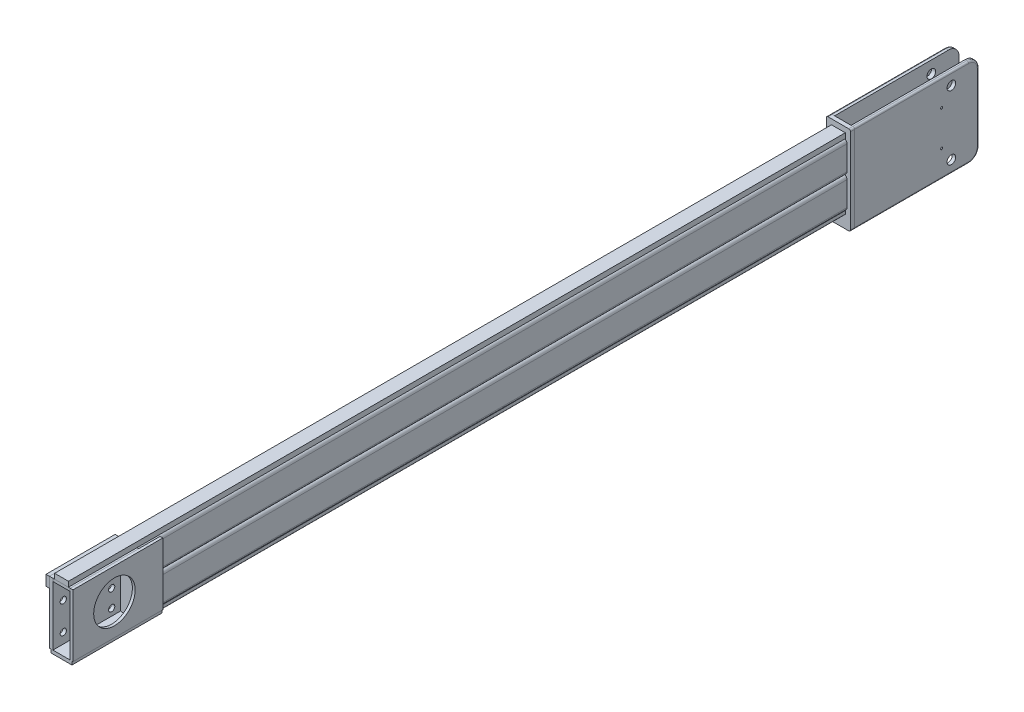
from build123d import *

# Parameters (mm, degrees)
MEMBER_90_60_5_1_DEPTH      = 2050
MEMBER_90_60_5_3_DEPTH      = 2050
EXTRUDE_1_DEPTH             = 8
EXTRUDE_2_DEPTH             = 12
SKETCH_16_W                 = 10
SKETCH_16_H                 = 256
EXTRUDE_3_DEPTH             = 360
SKETCH_16_W_2               = 12
EXTRUDE_3_2_DEPTH           = 360
FILLET_4_R                  = 30
FILLET_5_R                  = 30
FILLET_1_R                  = 5
FILLET_2_R                  = 5
SKETCH_17_W                 = 40
SKETCH_17_H                 = 1990
EXTRUDE_4_DEPTH             = 10
FILLET_6_R                  = 1
CUT_EXTRUDE_START           = -70
SKETCH_18_R                 = 12.5
CUT_EXTRUDE_1_DEPTH         = 70
HOLE_WIZARD_M6_1_AT_2_COUNT = 2
HOLE_WIZARD_M6_1_AT_2_PITCH = 101.5
SKETCH_21_W                 = 60
SKETCH_21_H                 = 10
EXTRUDE_5_DEPTH             = 190
SKETCH_22_W                 = 260
SKETCH_22_H                 = 180
EXTRUDE_6_DEPTH             = 10
SKETCH_23_W                 = 260
SKETCH_23_H                 = 180
EXTRUDE_7_DEPTH             = 8
SKETCH_24_W                 = 50
SKETCH_24_H                 = 198
EXTRUDE_9_DEPTH             = 8
SKETCH_25_R                 = 60
CUT_EXTRUDE_2_DEPTH         = 8
SKETCH_26_R                 = 9
CUT_EXTRUDE_3_DEPTH         = 10
SKETCH_27_W                 = 200
SKETCH_27_H                 = 30
EXTRUDE_10_DEPTH            = 10
SKETCH_34_W                 = 60
SKETCH_34_H                 = 10
EXTRUDE_15_DEPTH            = 70
SKETCH_29_R                 = 9
CUT_EXTRUDE_4_DEPTH         = 12
SKETCH_30_W                 = 290
SKETCH_30_H                 = 30
EXTRUDE_12_DEPTH            = 10
SKETCH_31_W                 = 50
SKETCH_31_H                 = 60
CUT_EXTRUDE_5_DEPTH         = 10
SKETCH_32_W                 = 60
SKETCH_32_H                 = 10
EXTRUDE_13_DEPTH            = 60
SKETCH_33_W                 = 40
SKETCH_33_H                 = 2248
EXTRUDE_14_DEPTH            = 15
SKETCH_37_W                 = 3.4
SKETCH_37_H                 = 5.001
HOLE_WIZARD_M8_1_AT_2_COUNT = 2
HOLE_WIZARD_M8_1_AT_2_PITCH = 80
HOLE_WIZARD_M8_1_AT_3_COUNT = 2
HOLE_WIZARD_M8_1_AT_3_PITCH = 40
HOLE_WIZARD_M8_1_AT_4_COUNT = 2
HOLE_WIZARD_M8_1_AT_4_PITCH = 89.4427191
SKETCH_38_R                 = 6
CUT_EXTRUDE_6_DEPTH         = 12


with BuildPart() as part:
    # 草图11 → Member 90_60_5_1 (new body)
    with BuildSketch(Plane(origin=(15, 55, 0), x_dir=(1, 0, 0), z_dir=(0, 0, -1))):
        with BuildLine():
            Line((-15, -35), (15, -35))
            ThreePointArc((15, -35), (22.071067812, -32.071067812), (25, -25))
            Line((25, -25), (25, 45))
            ThreePointArc((25, 45), (22.071067812, 52.071067812), (15, 55))
            Line((15, 55), (-15, 55))
            ThreePointArc((-15, 55), (-22.071067812, 52.071067812), (-25, 45))
            Line((-25, 45), (-25, -25))
            ThreePointArc((-25, -25), (-22.071067812, -32.071067812), (-15, -35))
        make_face()
        with BuildLine():
            Line((-15, 50), (15, 50))
            ThreePointArc((15, 50), (18.535533906, 48.535533906), (20, 45))
            Line((20, 45), (20, -25))
            ThreePointArc((20, -25), (18.535533906, -28.535533906), (15, -30))
            Line((15, -30), (-15, -30))
            ThreePointArc((-15, -30), (-18.535533906, -28.535533906), (-20, -25))
            Line((-20, -25), (-20, 45))
            ThreePointArc((-20, 45), (-18.535533906, 48.535533906), (-15, 50))
        make_face(mode=Mode.SUBTRACT)
    extrude(amount=MEMBER_90_60_5_1_DEPTH)


with BuildPart() as body_2:
    # 草图12 → Member 90_60_5_3 (new body)
    with BuildSketch(Plane(origin=(15, -35, 0), x_dir=(1, 0, 0), z_dir=(0, 0, -1))):
        with BuildLine():
            Line((-15, -35), (15, -35))
            ThreePointArc((15, -35), (22.071067812, -32.071067812), (25, -25))
            Line((25, -25), (25, 45))
            ThreePointArc((25, 45), (22.071067812, 52.071067812), (15, 55))
            Line((15, 55), (-15, 55))
            ThreePointArc((-15, 55), (-22.071067812, 52.071067812), (-25, 45))
            Line((-25, 45), (-25, -25))
            ThreePointArc((-25, -25), (-22.071067812, -32.071067812), (-15, -35))
        make_face()
        with BuildLine():
            Line((-15, 50), (15, 50))
            ThreePointArc((15, 50), (18.535533906, 48.535533906), (20, 45))
            Line((20, 45), (20, -25))
            ThreePointArc((20, -25), (18.535533906, -28.535533906), (15, -30))
            Line((15, -30), (-15, -30))
            ThreePointArc((-15, -30), (-18.535533906, -28.535533906), (-20, -25))
            Line((-20, -25), (-20, 45))
            ThreePointArc((-20, 45), (-18.535533906, 48.535533906), (-15, 50))
        make_face(mode=Mode.SUBTRACT)
    extrude(amount=MEMBER_90_60_5_3_DEPTH)



with BuildPart() as body_3:
    # 草图14 → 凸台-拉伸1 (new body)
    with BuildSketch(Plane.XY):
        with BuildLine():
            Line((45, 80), (45, -80))
            ThreePointArc((45, -80), (43.535533906, -83.535533906), (40, -85))
            Line((40, -85), (0, -85))
            ThreePointArc((0, -85), (-3.535533906, -83.535533906), (-5, -80))
            Line((-5, -80), (-5, 80))
            ThreePointArc((-5, 80), (-3.535533906, 83.535533906), (0, 85))
            Line((0, 85), (40, 85))
            ThreePointArc((40, 85), (43.535533906, 83.535533906), (45, 80))
        make_face()
    extrude(amount=EXTRUDE_1_DEPTH)


with BuildPart() as body_4:
    # 草图15 → 凸台-拉伸2 (new body)
    with BuildSketch(Plane(origin=(0, 0, -2050), x_dir=(-1, 0, 0), z_dir=(0, 0, -1))):
        with BuildLine():
            Line((-50, 115), (-50, -131))
            ThreePointArc((-50, -131), (-48.535533906, -134.535533906), (-45, -136))
            Line((-45, -136), (15, -136))
            ThreePointArc((15, -136), (18.535533906, -134.535533906), (20, -131))
            Line((20, -131), (20, 115))
            ThreePointArc((20, 115), (18.535533906, 118.535533906), (15, 120))
            Line((15, 120), (-45, 120))
            ThreePointArc((-45, 120), (-48.535533906, 118.535533906), (-50, 115))
        make_face()
    extrude(amount=EXTRUDE_2_DEPTH)


with BuildPart() as body_5:
    # 草图16 → 凸台-拉伸3 (new body)
    with BuildSketch(Plane(origin=(0, 0, -2062), x_dir=(-1, 0, 0), z_dir=(0, 0, -1))):
        with Locations((-45, -8)):
            Rectangle(SKETCH_16_W, SKETCH_16_H)
    extrude(amount=EXTRUDE_3_DEPTH)

    # 圆角4
    fillet_4_edges = [body_5.edges().sort_by_distance(p)[0] for p in [
        (45, -136, -2422),
        (45, 120, -2422),
    ]]
    fillet(fillet_4_edges, radius=FILLET_4_R)

    # 圆角1
    fillet_1_edges = [body_5.edges().sort_by_distance(p)[0] for p in [
        (50, -8, -2422),
        (50, -136, -2227),
        (50, 120, -2227),
        (50, 111.213203436, -2413.213203436),
        (50, -127.213203436, -2413.213203436),
    ]]
    fillet(fillet_1_edges, radius=FILLET_1_R)


with BuildPart() as body_6:
    # 草图16 → Extrude 3 2 (new body)
    with BuildSketch(Plane(origin=(0, 0, -2062), x_dir=(-1, 0, 0), z_dir=(0, 0, -1))):
        with Locations((14, -8)):
            Rectangle(SKETCH_16_W_2, SKETCH_16_H)
    extrude(amount=EXTRUDE_3_2_DEPTH)

    # 圆角5
    fillet_5_edges = [body_6.edges().sort_by_distance(p)[0] for p in [
        (-14, 120, -2422),
        (-14, -136, -2422),
    ]]
    fillet(fillet_5_edges, radius=FILLET_5_R)

    # 圆角2
    fillet_2_edges = [body_6.edges().sort_by_distance(p)[0] for p in [
        (-20, -8, -2422),
        (-20, 120, -2227),
        (-20, -136, -2227),
        (-20, 111.213203436, -2413.213203436),
        (-20, -127.213203436, -2413.213203436),
    ]]
    fillet(fillet_2_edges, radius=FILLET_2_R)


with BuildPart() as body_7:
    # 草图17 → 凸台-拉伸4 (new body)
    with BuildSketch(Plane.XZ.offset(90)):
        with Locations((15, -1055)):
            Rectangle(SKETCH_17_W, SKETCH_17_H)
    extrude(amount=EXTRUDE_4_DEPTH)

    # 圆角6
    fillet_6_edges = [body_7.edges().sort_by_distance(p)[0] for p in [
        (-5, -100, -1055),
        (35, -100, -1055),
    ]]
    fillet(fillet_6_edges, radius=FILLET_6_R)


with BuildPart() as cut_extrude_1_tool:
    # 草图18 → 切除-拉伸1 (new body)
    with BuildSketch(Plane.ZY.offset(20).offset(CUT_EXTRUDE_START)):
        with Locations(Location((-2342, 85, 0), (0, 0, 270))):
            Circle(SKETCH_18_R)
        with Locations(Location((-2342, -101, 0), (0, 0, 270))):
            Circle(SKETCH_18_R)
    extrude(amount=CUT_EXTRUDE_1_DEPTH)


with BuildPart() as body_5_1:
    add(body_5.part)

    # 切除-拉伸1: cut by cut_extrude_1_tool
    add(cut_extrude_1_tool.part, mode=Mode.SUBTRACT)

    # 草图20 → M6 螺纹孔1 (revolve, cut)
    with BuildSketch(Plane(origin=(50, 42.75, -2314), x_dir=(0, 0, -1), z_dir=(0, 1, 0))):
        Polygon((0, 0), (0, 10.001), (2.5, 10.001), (2.5, 0.525), (3.025, 0), align=None)
    hole_wizard_m6_1 = revolve(axis=Axis((56.35, 42.75, -2314), (-1, 0, 0)), mode=Mode.SUBTRACT)

    # M6 螺纹孔1 at 2: M6 螺纹孔1 ×2
    with Locations(*[(0, -i * HOLE_WIZARD_M6_1_AT_2_PITCH, 0) for i in range(1, HOLE_WIZARD_M6_1_AT_2_COUNT)]):
        add(hole_wizard_m6_1, mode=Mode.SUBTRACT)


with BuildPart() as body_6_1:
    add(body_6.part)

    # 切除-拉伸1: cut by cut_extrude_1_tool
    add(cut_extrude_1_tool.part, mode=Mode.SUBTRACT)

    # 草图29 → 切除-拉伸4 (cut)
    with BuildSketch(Plane.ZY.offset(20)):
        with Locations(Location((-2102, 30, 0), (0, 0, 270))):
            Circle(SKETCH_29_R)
        with Locations(Location((-2102, -20, 0), (0, 0, 270))):
            Circle(SKETCH_29_R)
        with Locations(Location((-2102, -70, 0), (0, 0, 270))):
            Circle(SKETCH_29_R)
        with Locations(Location((-2187, -20, 0), (0, 0, 270))):
            Circle(SKETCH_29_R)
        with Locations(Location((-2187, 30, 0), (0, 0, 270))):
            Circle(SKETCH_29_R)
        with Locations(Location((-2272, 20, 0), (0, 0, 270))):
            Circle(SKETCH_29_R)
        with Locations(Location((-2272, -50, 0), (0, 0, 270))):
            Circle(SKETCH_29_R)
        with Locations(Location((-2187, -70, 0), (0, 0, 270))):
            Circle(SKETCH_29_R)
    extrude(amount=-CUT_EXTRUDE_4_DEPTH, mode=Mode.SUBTRACT)

    # 草图38 → 切除-拉伸6 (cut)
    with BuildSketch(Plane.ZY.offset(20)):
        with Locations(Location((-2392, -56, 0), (0, 0, 270))):
            Circle(SKETCH_38_R)
        with Locations(Location((-2352, -26, 0), (0, 0, 270))):
            Circle(SKETCH_38_R)
        with Locations(Location((-2392, 4, 0), (0, 0, 270))):
            Circle(SKETCH_38_R)
    extrude(amount=-CUT_EXTRUDE_6_DEPTH, mode=Mode.SUBTRACT)


with BuildPart() as body_8:
    # 草图21 → 凸台-拉伸5 (new body)
    with BuildSketch(Plane.XY.offset(8)):
        with Locations((15, -95)):
            Rectangle(SKETCH_21_W, SKETCH_21_H)
    extrude(amount=EXTRUDE_5_DEPTH)


with BuildPart() as body_9:
    # 草图22 → 凸台-拉伸6 (new body)
    with BuildSketch(Plane.ZY.offset(10)):
        with Locations((68, 0)):
            Rectangle(SKETCH_22_W, SKETCH_22_H)
    extrude(amount=EXTRUDE_6_DEPTH)

    # 草图26 → 切除-拉伸3 (cut)
    with BuildSketch(Plane.ZY.offset(20)):
        with Locations(Location((98, -20, 0), (0, 0, 270))):
            Circle(SKETCH_26_R)
        with Locations(Location((98, 30, 0), (0, 0, 270))):
            Circle(SKETCH_26_R)
        with Locations(Location((98, -70, 0), (0, 0, 270))):
            Circle(SKETCH_26_R)
        with Locations(Location((168, -60, 0), (0, 0, 270))):
            Circle(SKETCH_26_R)
        with Locations(Location((168, 20, 0), (0, 0, 270))):
            Circle(SKETCH_26_R)
        with Locations(Location((28, -70, 0), (0, 0, 270))):
            Circle(SKETCH_26_R)
        with Locations(Location((28, -20, 0), (0, 0, 270))):
            Circle(SKETCH_26_R)
        with Locations(Location((28, 30, 0), (0, 0, 270))):
            Circle(SKETCH_26_R)
    extrude(amount=-CUT_EXTRUDE_3_DEPTH, mode=Mode.SUBTRACT)


with BuildPart() as body_10:
    # 草图23 → 凸台-拉伸7 (new body)
    with BuildSketch(Plane(origin=(40, 0, 0), x_dir=(0, 0, -1), z_dir=(1, 0, 0))):
        with Locations((-68, 0)):
            Rectangle(SKETCH_23_W, SKETCH_23_H)
    extrude(amount=EXTRUDE_7_DEPTH)

    # 草图25 → 切除-拉伸2 (cut)
    with BuildSketch(Plane(origin=(48, 0, 0), x_dir=(0, 0, -1), z_dir=(1, 0, 0))):
        with Locations(Location((-78, 0, 0), (0, 0, 90))):
            Circle(SKETCH_25_R)
    extrude(amount=-CUT_EXTRUDE_2_DEPTH, mode=Mode.SUBTRACT)


with BuildPart() as body_11:
    # 草图24 → 凸台-拉伸9 (new body)
    with BuildSketch(Plane(origin=(0, 90, 0), x_dir=(1, 0, 0), z_dir=(0, 1, 0))):
        with Locations((15, -99)):
            Rectangle(SKETCH_24_W, SKETCH_24_H)
    extrude(amount=-EXTRUDE_9_DEPTH)


with BuildPart() as body_12:
    # 草图27 → 凸台-拉伸10 (new body)
    with BuildSketch(Plane.ZY.offset(20)):
        with Locations((98, 75)):
            Rectangle(SKETCH_27_W, SKETCH_27_H)
    extrude(amount=EXTRUDE_10_DEPTH)


with BuildPart() as body_2_1:
    add(body_2.part)

    add(body_7.part)  # 凸台-拉伸15 merges body 7

    add(body_8.part)  # 凸台-拉伸15 merges body 8

    add(body_9.part)  # 凸台-拉伸15 merges body 9

    add(body_10.part)  # 凸台-拉伸15 merges body 10
    # 草图34 → 凸台-拉伸15 (add)
    with BuildSketch(Plane(origin=(0, 0, 8), x_dir=(-1, 0, 0), z_dir=(0, 0, -1))):
        with Locations((-15, -95)):
            Rectangle(SKETCH_34_W, SKETCH_34_H)
    extrude(amount=EXTRUDE_15_DEPTH)

    # 草图31 → 切除-拉伸5 (cut)
    with BuildSketch(Plane.XZ.offset(100)):
        with Locations((15, -32)):
            Rectangle(SKETCH_31_W, SKETCH_31_H)
    extrude(amount=-CUT_EXTRUDE_5_DEPTH, mode=Mode.SUBTRACT)

    # 草图37 → M8 螺纹孔的螺纹孔钻头1 (revolve, cut)
    with BuildSketch(Plane(origin=(-10, -65.505102572, -1772.019231054), x_dir=(0, 0, 1), z_dir=(0, 1, 0))):
        with Locations((1.7, 2.5005)):
            Rectangle(SKETCH_37_W, SKETCH_37_H)
    hole_wizard_m8_1 = revolve(axis=Axis((-16.35, -65.505102572, -1772.019231054), (1, 0, 0)), mode=Mode.SUBTRACT)

    # M8 螺纹孔的螺纹孔钻头1 at 2: M8 螺纹孔的螺纹孔钻头1 ×2
    with Locations(*[(0, 0, -i * HOLE_WIZARD_M8_1_AT_2_PITCH) for i in range(1, HOLE_WIZARD_M8_1_AT_2_COUNT)]):
        add(hole_wizard_m8_1, mode=Mode.SUBTRACT)

    # M8 螺纹孔的螺纹孔钻头1 at 3: M8 螺纹孔的螺纹孔钻头1 ×2
    with Locations(*[(0, i * HOLE_WIZARD_M8_1_AT_3_PITCH, 0) for i in range(1, HOLE_WIZARD_M8_1_AT_3_COUNT)]):
        add(hole_wizard_m8_1, mode=Mode.SUBTRACT)

    # M8 螺纹孔的螺纹孔钻头1 at 4: M8 螺纹孔的螺纹孔钻头1 ×2
    with Locations(*[Vector(1.5590314482392877e-15, 0.44721359549995787, -0.894427190999916) * (i * HOLE_WIZARD_M8_1_AT_4_PITCH) for i in range(1, HOLE_WIZARD_M8_1_AT_4_COUNT)]):
        add(hole_wizard_m8_1, mode=Mode.SUBTRACT)


with BuildPart() as body_9_2:
    # 草图30 → 凸台-拉伸12 (new body)
    with BuildSketch(Plane.ZY.offset(20)):
        with Locations((-2227, 75)):
            Rectangle(SKETCH_30_W, SKETCH_30_H)
    extrude(amount=EXTRUDE_12_DEPTH)


with BuildPart() as body_10_2:
    # 草图32 → 凸台-拉伸13 (new body)
    with BuildSketch(Plane(origin=(0, 0, -2), x_dir=(-1, 0, 0), z_dir=(0, 0, -1))):
        with Locations((-15, -95)):
            Rectangle(SKETCH_32_W, SKETCH_32_H)
    extrude(amount=EXTRUDE_13_DEPTH)


with BuildPart() as body_11_2:
    # 草图33 → 凸台-拉伸14 (new body)
    with BuildSketch(Plane(origin=(0, 90, 0), x_dir=(1, 0, 0), z_dir=(0, 1, 0))):
        with Locations((15, 926)):
            Rectangle(SKETCH_33_W, SKETCH_33_H)
    extrude(amount=EXTRUDE_14_DEPTH)


solid = Compound([part.part, body_3.part, body_4.part, body_5_1.part, body_6_1.part, body_11.part, body_12.part, body_2_1.part, body_9_2.part, body_10_2.part, body_11_2.part])
